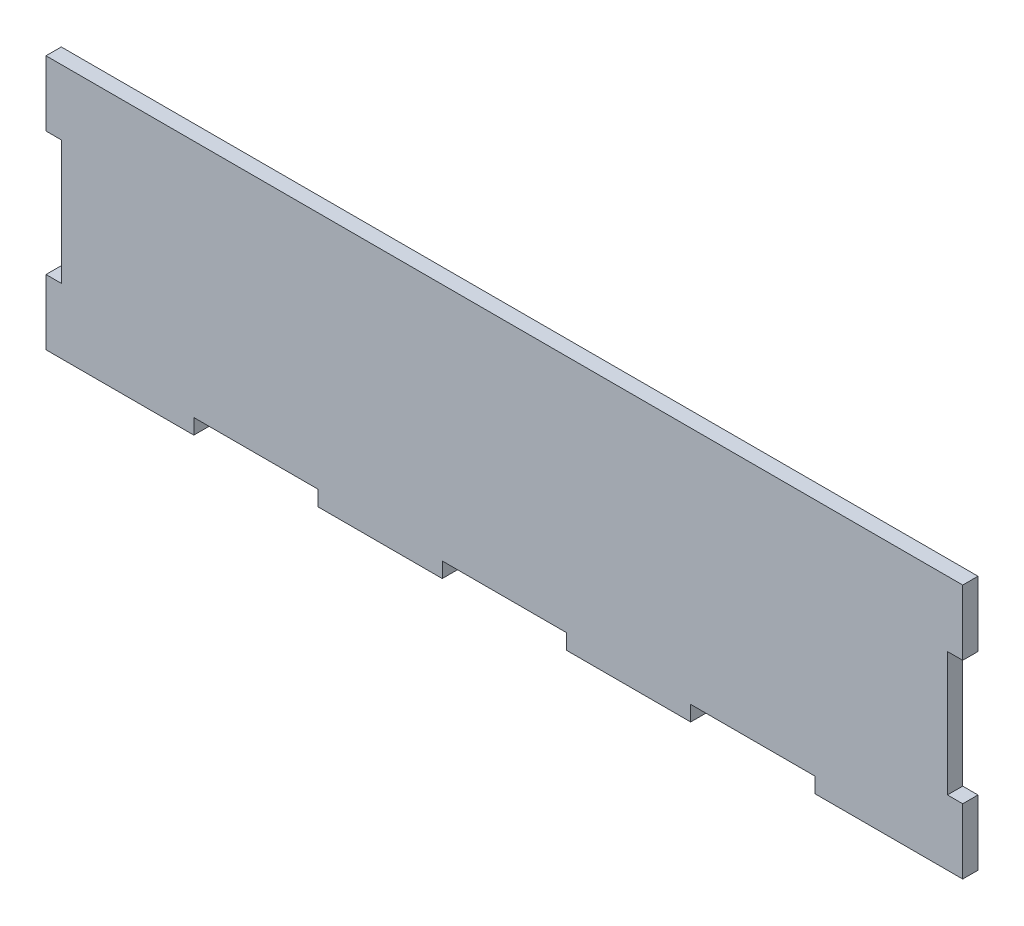
from build123d import *

# Parameters (mm, degrees)
SALIENTE_EXTRUIR1_DEPTH = 3


with BuildPart() as part:
    # Model → Saliente-Extruir1 (new body)
    with BuildSketch(Plane.XY):
        Polygon((0, 103), (0, 90.195), (3, 90.195), (3, 65.805), (0, 65.805), (0, 53), (29.025, 53), (29.025, 56), (53.415, 56), (53.415, 53), (77.805, 53), (77.805, 56), (102.195, 56), (102.195, 53), (126.585, 53), (126.585, 56), (150.975, 56), (150.975, 53), (175.365, 53), (180, 53), (180, 65.805), (177, 65.805), (177, 90.195), (180, 90.195), (180, 103), align=None)
    extrude(amount=SALIENTE_EXTRUIR1_DEPTH)


solid = part.part
